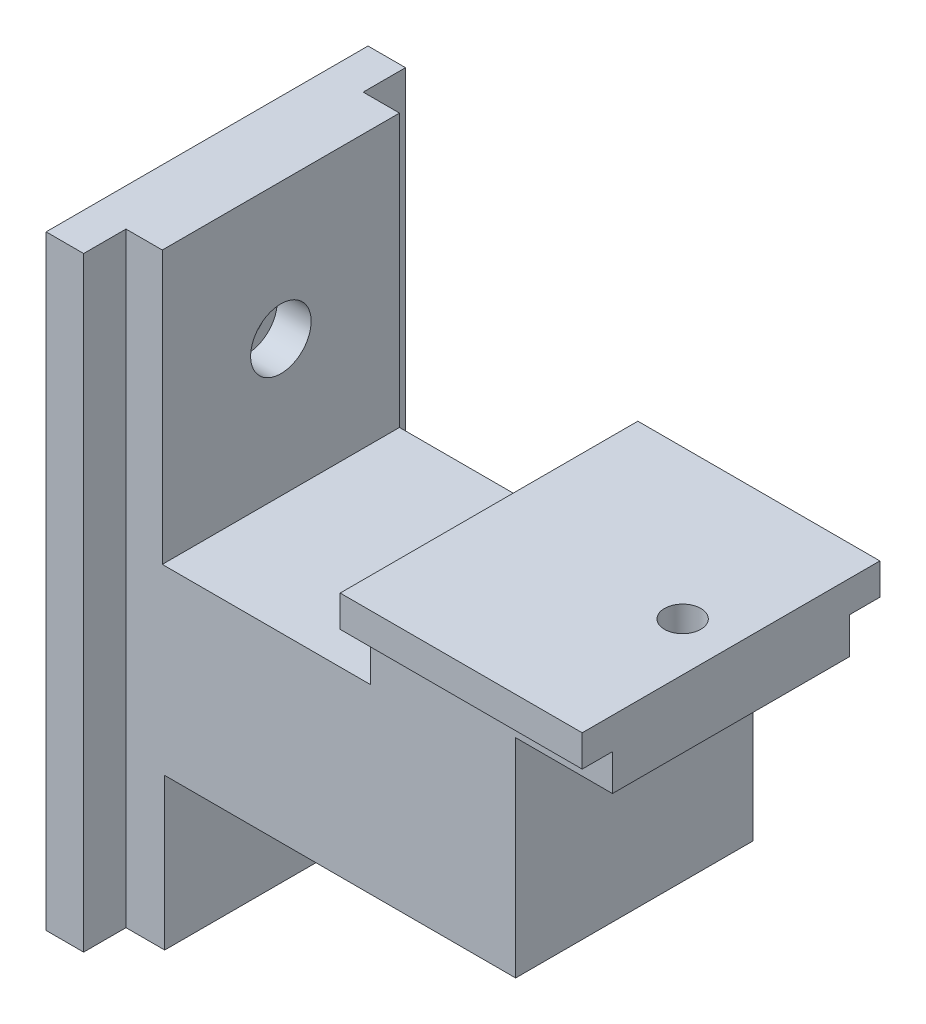
from build123d import *

# Parameters (mm, degrees)
BOSS_EXTRUDE1_DEPTH      = 10
BOSS_EXTRUDE2_DEPTH      = 30
BOSS_EXTRUDE2_DEPTH_BACK = 20
SKETCH3_W                = 20
SKETCH3_H                = 25
BOSS_EXTRUDE3_DEPTH      = 3
SKETCH4_W                = 20
SKETCH4_H                = 3
BOSS_EXTRUDE4_DEPTH      = 8
SKETCH5_R                = 1.5
CUT_EXTRUDE1_DEPTH       = 49.09105946
SKETCH5_3_R              = 2.5
SKETCH5_3_R_2            = 1.5
CUT_EXTRUDE2_DEPTH       = 2
SKETCH6_R                = 1.5
CUT_EXTRUDE3_DEPTH       = 6.5
SKETCH6_3_R              = 2.5
SKETCH6_3_R_2            = 1.5
CUT_EXTRUDE4_DEPTH       = 3
MOVE_FACE1_BY            = 0.2
MOVE_FACE1_2_BY          = 0.2
MOVE_FACE1_3_BY          = 0.2
MOVE_FACE1_4_BY          = 0.2
MOVE_FACE1_5_BY          = 0.2
MOVE_FACE1_6_BY          = 0.2
MOVE_FACE1_7_BY          = 0.2
MOVE_FACE1_8_BY          = 0.2
MOVE_FACE1_9_BY          = 0.2
MOVE_FACE1_10_BY         = 0.2
MOVE_FACE1_11_BY         = 0.2
MOVE_FACE1_12_BY         = 0.2
MOVE_FACE1_13_BY         = 0.2
MOVE_FACE1_14_BY         = 0.2


with BuildPart() as part:
    # Sketch1 → Boss-Extrude1 (new, symmetric)
    with BuildSketch(Plane.XY):
        Polygon((0, -7.5), (-32, -7.5), (-32, 7.5), (-12, 7.5), (-12, 12.5), (0, 12.5), align=None)
    extrude(amount=BOSS_EXTRUDE1_DEPTH, both=True)

    # Sketch2 → Boss-Extrude2 (add, two sides)
    with BuildSketch(Plane(origin=(0, 0, 0), x_dir=(1, 0, 0), z_dir=(0, 1, 0))) as boss_extrude2_sk:
        Polygon((-32, 13.5), (-35.5, 13.5), (-35.5, -13.5), (-32, -13.5), (-32, -10), (-29, -10), (-29, 10), (-32, 10), align=None)
    extrude(amount=BOSS_EXTRUDE2_DEPTH)
    extrude(boss_extrude2_sk.sketch, amount=-BOSS_EXTRUDE2_DEPTH_BACK)

    # Sketch3 → Boss-Extrude3 (add)
    with BuildSketch(Plane(origin=(0, 12.5, 0), x_dir=(1, 0, 0), z_dir=(0, 1, 0))):
        with Locations((-2, 0)):
            Rectangle(SKETCH3_W, SKETCH3_H)
    extrude(amount=BOSS_EXTRUDE3_DEPTH)

    # Sketch4 → Boss-Extrude4 (add)
    with BuildSketch(Plane(origin=(0, 0, 0), x_dir=(0, 0, -1), z_dir=(1, 0, 0))):
        with Locations((0, 11)):
            Rectangle(SKETCH4_W, SKETCH4_H)
    extrude(amount=BOSS_EXTRUDE4_DEPTH)

    # Sketch5 → Cut-Extrude1 (cut, through all)
    with BuildSketch(Plane.XZ.offset(-9.5)):
        with Locations((4, 0)):
            Circle(SKETCH5_R)
    extrude(amount=-CUT_EXTRUDE1_DEPTH, mode=Mode.SUBTRACT)

    # Sketch5_3 → Cut-Extrude2 (cut)
    with BuildSketch(Plane.XZ.offset(-9.5)):
        with Locations((4, 0)):
            Circle(SKETCH5_3_R)
        with Locations((4, 0)):
            Circle(SKETCH5_3_R_2, mode=Mode.SUBTRACT)
    extrude(amount=-CUT_EXTRUDE2_DEPTH, mode=Mode.SUBTRACT)

    # Sketch6 → Cut-Extrude3 (cut)
    with BuildSketch(Plane(origin=(-29, 0, 0), x_dir=(0, 0, -1), z_dir=(1, 0, 0))):
        with Locations((0, 18.75)):
            Circle(SKETCH6_R)
    extrude(amount=-CUT_EXTRUDE3_DEPTH, mode=Mode.SUBTRACT)

    # Sketch6_3 → Cut-Extrude4 (cut)
    with BuildSketch(Plane(origin=(-29, 0, 0), x_dir=(0, 0, -1), z_dir=(1, 0, 0))):
        with Locations((0, 18.75)):
            Circle(SKETCH6_3_R)
        with Locations((0, 18.75)):
            Circle(SKETCH6_3_R_2, mode=Mode.SUBTRACT)
    extrude(amount=-CUT_EXTRUDE4_DEPTH, mode=Mode.SUBTRACT)

    # Move Face1: a face moved inward by 0.2
    extrude(part.faces().sort_by_distance((7.2, 9.5, 0))[0], amount=MOVE_FACE1_BY, dir=(0, 1, 0), mode=Mode.SUBTRACT)

    # Move Face1 2: a face moved inward by 0.2
    extrude(part.faces().sort_by_distance((-29, 24.375, 0))[0], amount=MOVE_FACE1_2_BY, dir=(-1, 0, 0), mode=Mode.SUBTRACT)

    # Move Face1 3: a face moved inward by 0.2
    extrude(part.faces().sort_by_distance((-2, 12.5, -11.25))[0], amount=MOVE_FACE1_3_BY, dir=(0, 1, 0), mode=Mode.SUBTRACT)

    # Move Face1 4: a face moved inward by 0.2
    extrude(part.faces().sort_by_distance((-2, 14, -12.5))[0], amount=MOVE_FACE1_4_BY, dir=(0, 0, 1), mode=Mode.SUBTRACT)

    # Move Face1 5: a face moved inward by 0.2
    extrude(part.faces().sort_by_distance((-2.086039354, 15.5, 0))[0], amount=MOVE_FACE1_5_BY, dir=(0, -1, 0), mode=Mode.SUBTRACT)

    # Move Face1 6: a face moved inward by 0.2
    extrude(part.faces().sort_by_distance((-2, 14, 12.5))[0], amount=MOVE_FACE1_6_BY, dir=(0, 0, -1), mode=Mode.SUBTRACT)

    # Move Face1 7: a face moved inward by 0.2
    extrude(part.faces().sort_by_distance((-2, 12.5, 11.25))[0], amount=MOVE_FACE1_7_BY, dir=(0, 1, 0), mode=Mode.SUBTRACT)

    # Move Face1 8: a face moved inward by 0.2
    extrude(part.faces().sort_by_distance((-33.75, 5, -13.5))[0], amount=MOVE_FACE1_8_BY, dir=(0, 0, 1), mode=Mode.SUBTRACT)

    # Move Face1 9: a face moved inward by 0.2
    extrude(part.faces().sort_by_distance((-32, 5, -11.75))[0], amount=MOVE_FACE1_9_BY, dir=(-1, 0, 0), mode=Mode.SUBTRACT)

    # Move Face1 10: a face moved inward by 0.2
    extrude(part.faces().sort_by_distance((-16.661434978, 2.412556054, -10))[0], amount=MOVE_FACE1_10_BY, dir=(0, 0, 1), mode=Mode.SUBTRACT)

    # Move Face1 11: a face moved inward by 0.2
    extrude(part.faces().sort_by_distance((-35.5, 4.92762622, 0))[0], amount=MOVE_FACE1_11_BY, dir=(1, 0, 0), mode=Mode.SUBTRACT)

    # Move Face1 12: a face moved inward by 0.2
    extrude(part.faces().sort_by_distance((-16.661434978, 2.412556054, 10))[0], amount=MOVE_FACE1_12_BY, dir=(0, 0, -1), mode=Mode.SUBTRACT)

    # Move Face1 13: a face moved inward by 0.2
    extrude(part.faces().sort_by_distance((-32, 5, 11.75))[0], amount=MOVE_FACE1_13_BY, dir=(-1, 0, 0), mode=Mode.SUBTRACT)

    # Move Face1 14: a face moved inward by 0.2
    extrude(part.faces().sort_by_distance((-33.75, 5, 13.5))[0], amount=MOVE_FACE1_14_BY, dir=(0, 0, -1), mode=Mode.SUBTRACT)


solid = part.part
